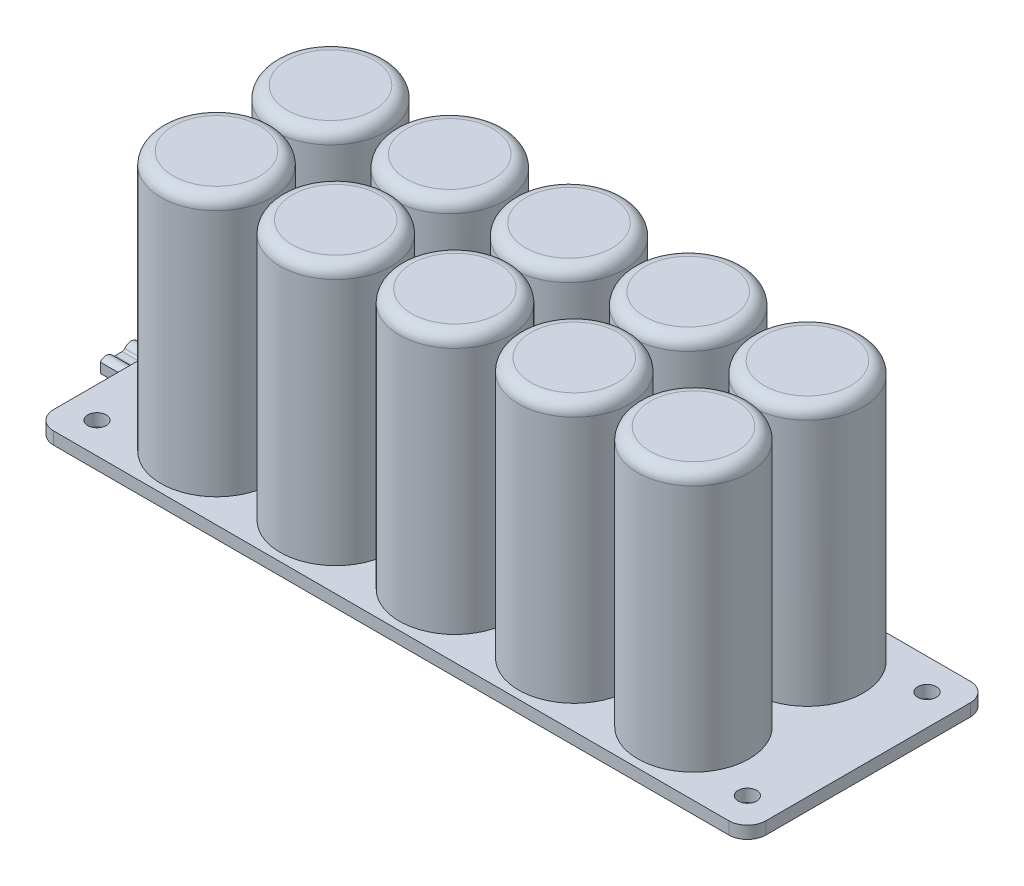
from build123d import *

# Parameters (mm, degrees)
EXTRUDE_1_DEPTH     = 2
SKETCH_2_R          = 9
EXTRUDE_3_DEPTH     = 42
FILLET_1_R          = 2
SKETCH_4_R          = 1.5
CUT_EXTRUDE_1_DEPTH = 45.0000001
SKETCH_5_W          = 13
SKETCH_5_H          = 3.85
EXTRUDE_4_DEPTH     = 10
SKETCH_6_R          = 0.75
EXTRUDE_5_DEPTH     = 6


with BuildPart() as part:
    # 草图1 → 凸台-拉伸1 (new body)
    with BuildSketch(Plane(origin=(0, 0, 0), x_dir=(1, 0, 0), z_dir=(0, 1, 0))):
        with BuildLine():
            Line((-54.5, 19.5), (54.5, 19.5))
            ThreePointArc((54.5, 19.5), (56.621320344, 18.621320344), (57.5, 16.5))
            Line((57.5, 16.5), (57.5, -16.5))
            ThreePointArc((57.5, -16.5), (56.621320344, -18.621320344), (54.5, -19.5))
            Line((54.5, -19.5), (-54.5, -19.5))
            ThreePointArc((-54.5, -19.5), (-56.621320344, -18.621320344), (-57.5, -16.5))
            Line((-57.5, -16.5), (-57.5, 16.5))
            ThreePointArc((-57.5, 16.5), (-56.621320344, 18.621320344), (-54.5, 19.5))
        make_face()
    extrude(amount=EXTRUDE_1_DEPTH)

    # 草图2 → 凸台-拉伸3 (add)
    with BuildSketch(Plane(origin=(0, 2, 0), x_dir=(1, 0, 0), z_dir=(0, 1, 0))):
        with Locations((0, 9.2)):
            Circle(SKETCH_2_R)
        with Locations((-19.25, 9.2)):
            Circle(SKETCH_2_R)
        with Locations((-38.5, 9.2)):
            Circle(SKETCH_2_R)
        with Locations((19.25, 9.2)):
            Circle(SKETCH_2_R)
        with Locations((38.5, 9.2)):
            Circle(SKETCH_2_R)
        with Locations((38.5, -9.2)):
            Circle(SKETCH_2_R)
        with Locations((19.25, -9.2)):
            Circle(SKETCH_2_R)
        with Locations((-38.5, -9.2)):
            Circle(SKETCH_2_R)
        with Locations((-19.25, -9.2)):
            Circle(SKETCH_2_R)
        with Locations((0, -9.2)):
            Circle(SKETCH_2_R)
    extrude(amount=EXTRUDE_3_DEPTH)

    # 圆角1
    fillet_1_edges = [part.edges().sort_by_distance(p)[0] for p in [
        (-9, 44, -9.2),
        (-28.25, 44, -9.2),
        (-47.5, 44, -9.2),
        (10.25, 44, -9.2),
        (29.5, 44, -9.2),
        (29.5, 44, 9.2),
        (10.25, 44, 9.2),
        (-47.5, 44, 9.2),
        (-28.25, 44, 9.2),
        (-9, 44, 9.2),
    ]]
    fillet(fillet_1_edges, radius=FILLET_1_R)

    # 草图4 → 切除-拉伸1 (cut, through all)
    with BuildSketch(Plane.XZ):
        with Locations((-52.5, 14.5)):
            Circle(SKETCH_4_R)
        with Locations((-52.5, -14.5)):
            Circle(SKETCH_4_R)
        with Locations((52.5, -14.5)):
            Circle(SKETCH_4_R)
        with Locations((52.5, 14.5)):
            Circle(SKETCH_4_R)
    extrude(amount=-CUT_EXTRUDE_1_DEPTH, mode=Mode.SUBTRACT)

    # 草图5 → 凸台-拉伸4 (add)
    with BuildSketch(Plane.ZY.offset(57.5)):
        with Locations((0, -1.925)):
            Rectangle(SKETCH_5_W, SKETCH_5_H)
    extrude(amount=-EXTRUDE_4_DEPTH)

    # 草图6 → 凸台-拉伸5 (add)
    with BuildSketch(Plane.ZY.offset(57.5)):
        with BuildLine():
            Line((-0.563859338, -1.425), (0.563859338, -1.425))
            ThreePointArc((0.563859338, -1.425), (0.795314363, -1.36820263), (0.974185242, -1.210714286))
            ThreePointArc((0.974185242, -1.210714286), (1.954468576, -0.675829519), (2.971091293, -1.137928402))
            Line((2.971091293, -1.137928402), (2.971091293, -2.712071598))
            ThreePointArc((2.971091293, -2.712071598), (1.954468576, -3.174170481), (0.974185242, -2.639285714))
            ThreePointArc((0.974185242, -2.639285714), (0.795314363, -2.48179737), (0.563859338, -2.425))
            Line((0.563859338, -2.425), (-0.563859338, -2.425))
            ThreePointArc((-0.563859338, -2.425), (-0.795314363, -2.48179737), (-0.974185242, -2.639285714))
            ThreePointArc((-0.974185242, -2.639285714), (-3.25, -1.925), (-0.974185242, -1.210714286))
            ThreePointArc((-0.974185242, -1.210714286), (-0.795314363, -1.36820263), (-0.563859338, -1.425))
        make_face()
        with Locations((-2, -1.925)):
            Circle(SKETCH_6_R, mode=Mode.SUBTRACT)
        with Locations((2, -1.925)):
            Circle(SKETCH_6_R, mode=Mode.SUBTRACT)
    extrude(amount=EXTRUDE_5_DEPTH)


solid = part.part
